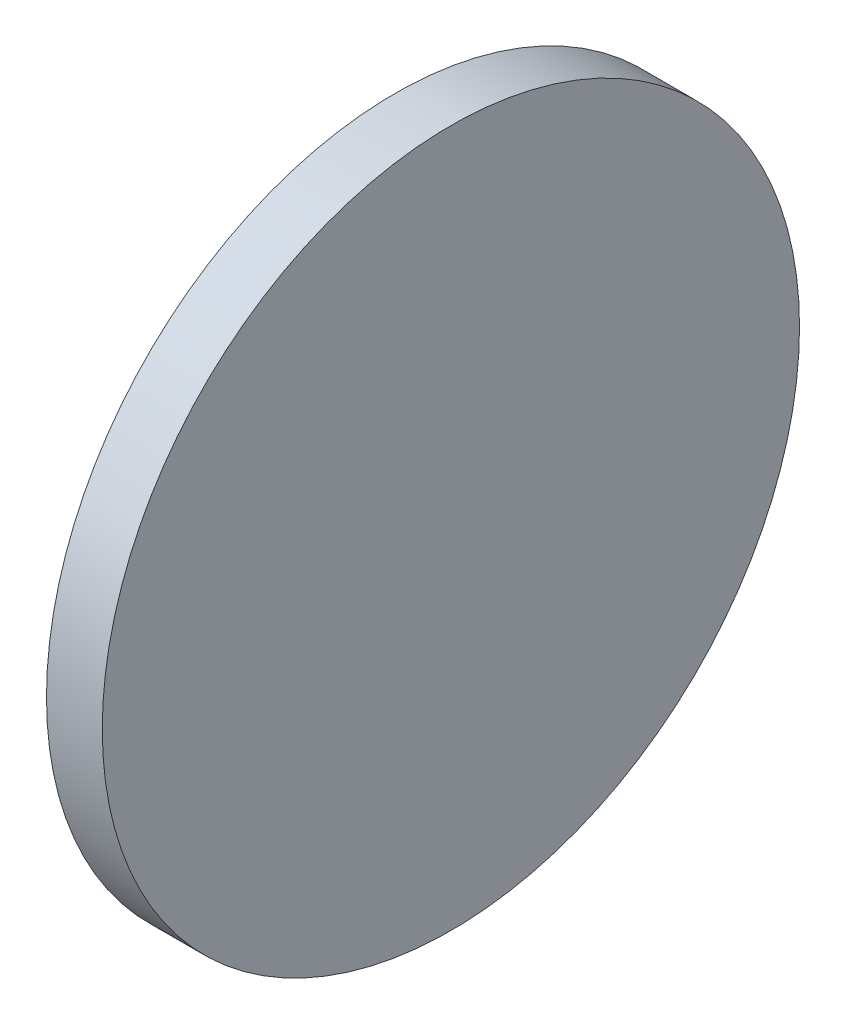
from build123d import *

# Parameters (mm, degrees)
SKETCH_1_W = 2
SKETCH_1_H = 12.5


with BuildPart() as part:
    # 草图1 → 旋转1 (revolve)
    with BuildSketch(Plane.XY, mode=Mode.PRIVATE) as revolve_1_sk:
        with Locations((261.286208168, 83.543179349)):
            Rectangle(SKETCH_1_W, SKETCH_1_H)
    revolve(revolve_1_sk.sketch.rotate(Axis((254.000801993, 77.293179349, 0), (1, 0, 0)), 90), axis=Axis((254.000801993, 77.293179349, 0), (1, 0, 0)))  # turned: the seam where the file's is


solid = part.part
